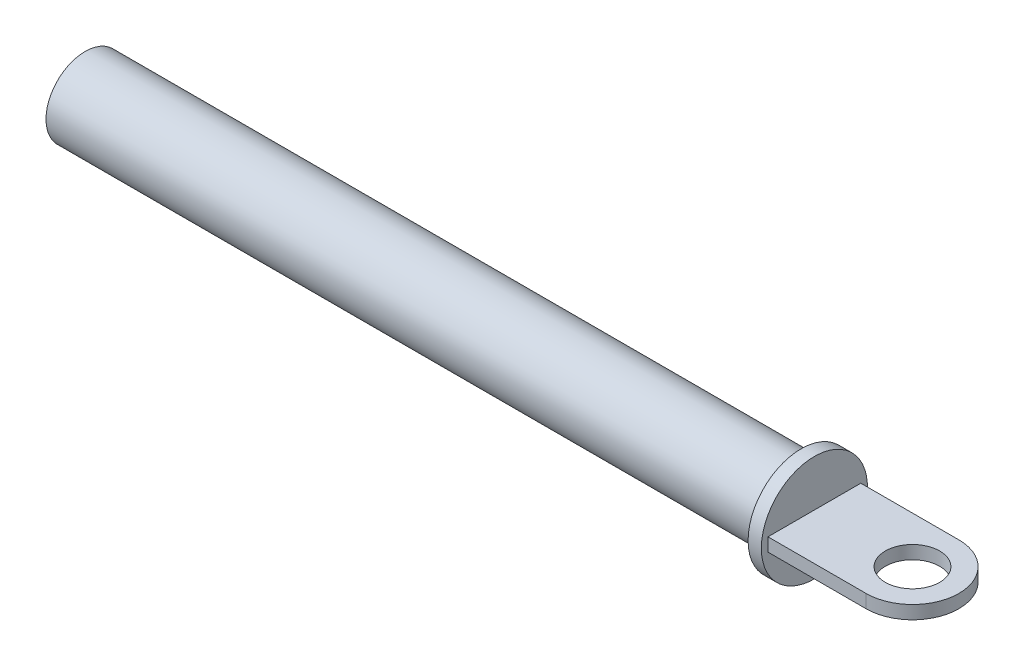
from build123d import *

# Parameters (mm, degrees)
SKETCH1_W                  = 1
SKETCH1_H                  = 4
BOSS_EXTRUDE1_DEPTH        = 1
SKETCH3_R                  = 2.95
BOSS_EXTRUDE2_DEPTH        = 54
F_4_1_4_1_DIAMETER_HOLE1_D = 4.1


with BuildPart() as part:
    # Sketch1 → Revolve1 (revolve)
    with BuildSketch(Plane(origin=(0, 0, 0), x_dir=(-1, 0, 0), z_dir=(0, 0, -1))):
        with Locations((-32.5, 2)):
            Rectangle(SKETCH1_W, SKETCH1_H)
    revolve(axis=Axis((33, 0, 0), (-1, 0, 0)))

    # Sketch2 → Boss-Extrude1 (add)
    with BuildSketch(Plane(origin=(0, 0.5, 0), x_dir=(1, 0, 0), z_dir=(0, 1, 0))):
        with BuildLine():
            Line((33, 3.5), (33, -3.5))
            Line((33, -3.5), (40.398405894, -3.5))
            ThreePointArc((40.398405894, -3.5), (43.898405894, 0), (40.398405894, 3.5))
            Line((40.398405894, 3.5), (33, 3.5))
        make_face()
    extrude(amount=-BOSS_EXTRUDE1_DEPTH)

    # Sketch3 → Boss-Extrude2 (add)
    with BuildSketch(Plane.ZY.offset(-32)):
        Circle(SKETCH3_R)
    extrude(amount=BOSS_EXTRUDE2_DEPTH)

    # Ø4.1 (4.1) Diameter Hole1 (through all)
    with Locations(Plane(origin=(0, -0.5, 0), x_dir=(-1, 0, 0), z_dir=(0, -1, 0))):
        with Locations((-40.398405894, 0)):
            Hole(F_4_1_4_1_DIAMETER_HOLE1_D / 2)


solid = part.part
